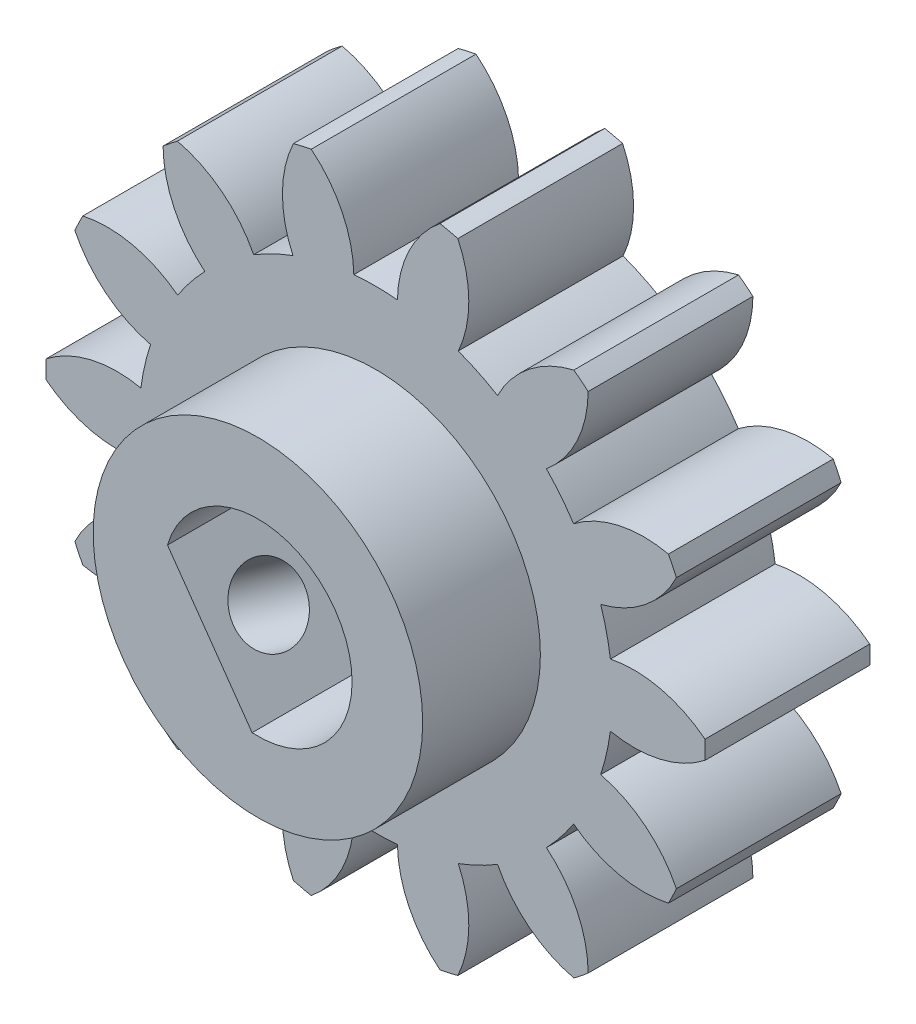
from build123d import *

# Parameters (mm, degrees)
BOSS_EXTRUDE1_DEPTH = 7
SKETCH2_R           = 7
SKETCH2_R_2         = 4
BOSS_EXTRUDE2_DEPTH = 5
SKETCH3_R           = 4
CUT_EXTRUDE1_DEPTH  = 15
BOSS_EXTRUDE3_DEPTH = 12
SKETCH5_R           = 1.5
CUT_EXTRUDE2_DEPTH  = 12


with BuildPart() as part:
    # Sketch1 → Boss-Extrude1 (new body)
    with BuildSketch(Plane.XY):
        with BuildLine():
            ThreePointArc((-12.439687438, -6.422941417), (-10.325628022, -6.417742109), (-8.410516827, -5.522407894))
            ThreePointArc((-8.410516827, -5.522407894), (-7.866397461, -6.273242641), (-7.255465658, -6.970796248))
            ThreePointArc((-7.255465658, -6.970796248), (-8.554504306, -8.638661002), (-9.029995733, -10.698559579))
            ThreePointArc((-9.029995733, -10.698559579), (-8.728857226, -10.945640755), (-8.42096127, -11.184248356))
            ThreePointArc((-8.42096127, -11.184248356), (-6.518515447, -10.262307937), (-5.181530838, -8.624704077))
            ThreePointArc((-5.181530838, -8.624704077), (-4.365521241, -9.065098264), (-3.512433539, -9.428498973))
            ThreePointArc((-3.512433539, -9.428498973), (-3.959167524, -11.494824938), (-3.493813999, -13.557037425))
            ThreePointArc((-3.493813999, -13.557037425), (-3.115293075, -13.648990771), (-2.734360446, -13.730377742))
            ThreePointArc((-2.734360446, -13.730377742), (-1.420330943, -12.07429782), (-0.926279119, -10.018771843))
            ThreePointArc((-0.926279119, -10.018771843), (0, -10.0615), (0.926279119, -10.018771843))
            ThreePointArc((0.926279119, -10.018771843), (1.420330943, -12.07429782), (2.734360446, -13.730377742))
            ThreePointArc((2.734360446, -13.730377742), (3.115293075, -13.648990771), (3.493813999, -13.557037425))
            ThreePointArc((3.493813999, -13.557037425), (3.959167524, -11.494824938), (3.512433539, -9.428498973))
            ThreePointArc((3.512433539, -9.428498973), (4.365521241, -9.065098264), (5.181530838, -8.624704077))
            ThreePointArc((5.181530838, -8.624704077), (6.518515447, -10.262307937), (8.42096127, -11.184248356))
            ThreePointArc((8.42096127, -11.184248356), (8.728857226, -10.945640755), (9.029995733, -10.698559579))
            ThreePointArc((9.029995733, -10.698559579), (8.554504306, -8.638661002), (7.255465658, -6.970796248))
            ThreePointArc((7.255465658, -6.970796248), (7.866397461, -6.273242641), (8.410516827, -5.522407894))
            ThreePointArc((8.410516827, -5.522407894), (10.325628022, -6.417742109), (12.439687438, -6.422941417))
            ThreePointArc((12.439687438, -6.422941417), (12.613564151, -6.074372348), (12.777676066, -5.7211008))
            ThreePointArc((12.777676066, -5.7211008), (11.455516597, -4.071504309), (9.561463821, -3.132441835))
            ThreePointArc((9.561463821, -3.132441835), (9.809237188, -2.238894377), (9.97369681, -1.3263311))
            ThreePointArc((9.97369681, -1.3263311), (12.087623332, -1.302063747), (13.994580946, -0.389492158))
            ThreePointArc((13.994580946, -0.389492158), (14, 0), (13.994580946, 0.389492158))
            ThreePointArc((13.994580946, 0.389492158), (12.087623332, 1.302063747), (9.97369681, 1.3263311))
            ThreePointArc((9.97369681, 1.3263311), (9.809237188, 2.238894377), (9.561463821, 3.132441835))
            ThreePointArc((9.561463821, 3.132441835), (11.455516597, 4.071504309), (12.777676066, 5.7211008))
            ThreePointArc((12.777676066, 5.7211008), (12.613564151, 6.074372348), (12.439687438, 6.422941417))
            ThreePointArc((12.439687438, 6.422941417), (10.325628022, 6.417742109), (8.410516827, 5.522407894))
            ThreePointArc((8.410516827, 5.522407894), (7.866397461, 6.273242641), (7.255465658, 6.970796248))
            ThreePointArc((7.255465658, 6.970796248), (8.554504306, 8.638661002), (9.029995733, 10.698559579))
            ThreePointArc((9.029995733, 10.698559579), (8.728857226, 10.945640755), (8.42096127, 11.184248356))
            ThreePointArc((8.42096127, 11.184248356), (6.518515447, 10.262307937), (5.181530838, 8.624704077))
            ThreePointArc((5.181530838, 8.624704077), (4.365521241, 9.065098264), (3.512433539, 9.428498973))
            ThreePointArc((3.512433539, 9.428498973), (3.959167524, 11.494824938), (3.493813999, 13.557037425))
            ThreePointArc((3.493813999, 13.557037425), (3.115293075, 13.648990771), (2.734360446, 13.730377742))
            ThreePointArc((2.734360446, 13.730377742), (1.420330943, 12.07429782), (0.926279119, 10.018771843))
            ThreePointArc((0.926279119, 10.018771843), (0, 10.0615), (-0.926279119, 10.018771843))
            ThreePointArc((-0.926279119, 10.018771843), (-1.420330943, 12.07429782), (-2.734360446, 13.730377742))
            ThreePointArc((-2.734360446, 13.730377742), (-3.115293075, 13.648990771), (-3.493813999, 13.557037425))
            ThreePointArc((-3.493813999, 13.557037425), (-3.959167524, 11.494824938), (-3.512433539, 9.428498973))
            ThreePointArc((-3.512433539, 9.428498973), (-4.365521241, 9.065098264), (-5.181530838, 8.624704077))
            ThreePointArc((-5.181530838, 8.624704077), (-6.518515447, 10.262307937), (-8.42096127, 11.184248356))
            ThreePointArc((-8.42096127, 11.184248356), (-8.728857226, 10.945640755), (-9.029995733, 10.698559579))
            ThreePointArc((-9.029995733, 10.698559579), (-8.554504306, 8.638661002), (-7.255465658, 6.970796248))
            ThreePointArc((-7.255465658, 6.970796248), (-7.866397461, 6.273242641), (-8.410516827, 5.522407894))
            ThreePointArc((-8.410516827, 5.522407894), (-10.325628022, 6.417742109), (-12.439687438, 6.422941417))
            ThreePointArc((-12.439687438, 6.422941417), (-12.613564151, 6.074372348), (-12.777676066, 5.7211008))
            ThreePointArc((-12.777676066, 5.7211008), (-11.455516597, 4.071504309), (-9.561463821, 3.132441835))
            ThreePointArc((-9.561463821, 3.132441835), (-9.809237188, 2.238894377), (-9.97369681, 1.3263311))
            ThreePointArc((-9.97369681, 1.3263311), (-12.087623332, 1.302063747), (-13.994580946, 0.389492158))
            ThreePointArc((-13.994580946, 0.389492158), (-14, 0), (-13.994580946, -0.389492158))
            ThreePointArc((-13.994580946, -0.389492158), (-12.087623332, -1.302063747), (-9.97369681, -1.3263311))
            ThreePointArc((-9.97369681, -1.3263311), (-9.809237188, -2.238894377), (-9.561463821, -3.132441835))
            ThreePointArc((-9.561463821, -3.132441835), (-11.455516597, -4.071504309), (-12.777676066, -5.7211008))
            ThreePointArc((-12.777676066, -5.7211008), (-12.613564151, -6.074372348), (-12.439687438, -6.422941417))
        make_face()
    extrude(amount=BOSS_EXTRUDE1_DEPTH)

    # Sketch2 → Boss-Extrude2 (add)
    with BuildSketch(Plane.XY.offset(7)):
        Circle(SKETCH2_R)
        Circle(SKETCH2_R_2, mode=Mode.SUBTRACT)
    extrude(amount=BOSS_EXTRUDE2_DEPTH)

    # Sketch3 → Cut-Extrude1 (cut)
    with BuildSketch(Plane.XY.offset(7)):
        Circle(SKETCH3_R)
    extrude(amount=-CUT_EXTRUDE1_DEPTH, mode=Mode.SUBTRACT)

    # Sketch4 → Boss-Extrude3 (add)
    with BuildSketch(Plane(origin=(0, 0, 0), x_dir=(-1, 0, 0), z_dir=(0, 0, -1))):
        with BuildLine():
            Line((3.841780502, 1.113877271), (0.246510723, -3.992396832))
            ThreePointArc((0.246510723, -3.992396832), (3.27063298, -2.302815648), (3.841780502, 1.113877271))
        make_face()
    extrude(amount=-BOSS_EXTRUDE3_DEPTH)

    # Sketch5 → Cut-Extrude2 (cut)
    with BuildSketch(Plane(origin=(-10.220728062, -7.196298901, 0), x_dir=(0, 0, -1), z_dir=(0.817658245, 0.575703912, 0))):
        with Locations((-9.5, 0)):
            Circle(SKETCH5_R)
    extrude(amount=CUT_EXTRUDE2_DEPTH, mode=Mode.SUBTRACT)


solid = part.part
